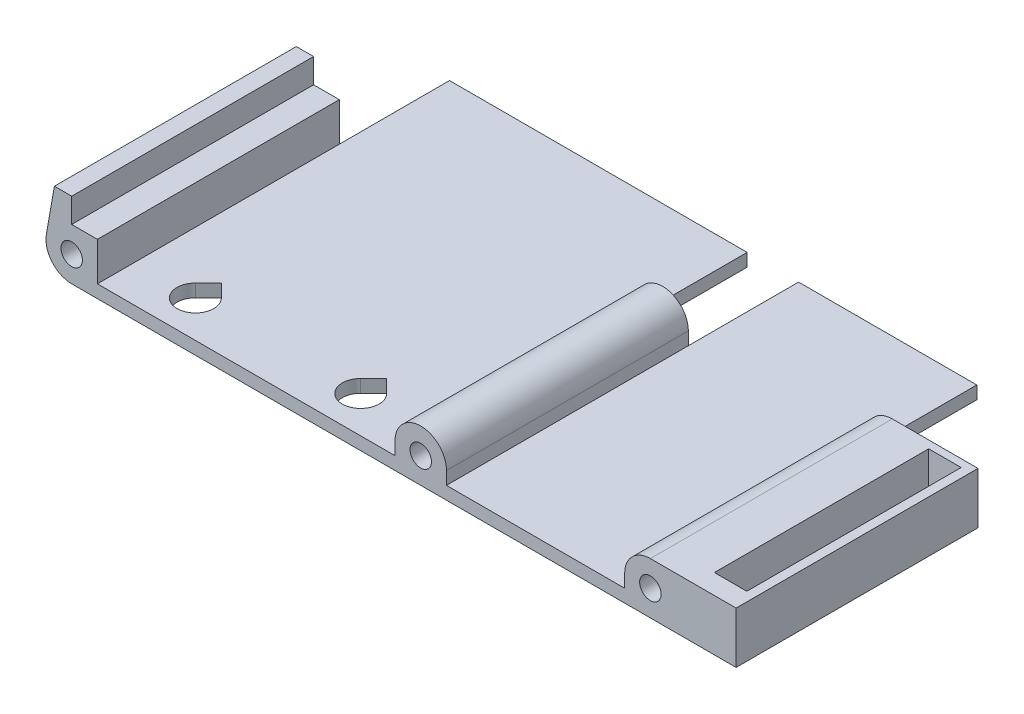
from build123d import *

# Parameters (mm, degrees)
SKETCH1_R           = 1.75
BOSS_EXTRUDE1_DEPTH = 57.5
BOSS_EXTRUDE2_DEPTH = 8.4
SKETCH3_W           = 5.3
SKETCH3_H           = 35
CUT_EXTRUDE1_DEPTH  = 5.4
CUT_EXTRUDE2_DEPTH  = 3.1
SKETCH5_W           = 18.2
SKETCH5_H           = 8.4
SKETCH5_W_2         = 8.4
SKETCH5_H_2         = 8.937392322
SKETCH5_W_3         = 9.875614017
SKETCH5_H_3         = 12.4
CUT_EXTRUDE3_DEPTH  = 18
LPATTERN1_COUNT     = 2
LPATTERN1_PITCH     = 27


with BuildPart() as part:
    # Sketch1 → Boss-Extrude1 (new body)
    with BuildSketch(Plane.XY):
        with BuildLine():
            Line((-52.8, -2.1), (-4.2, -2.1))
            Line((-4.2, -2.1), (-4.2, 0))
            ThreePointArc((-4.2, 0), (0, 4.2), (4.2, 0))
            Line((4.2, 0), (4.2, -2.1))
            Line((4.2, -2.1), (33.3, -2.1))
            Line((33.3, -2.1), (33.3, 0))
            ThreePointArc((33.3, 0), (34.530151519, 2.969848481), (37.5, 4.2))
            Line((37.5, 4.2), (41.5, 4.2))
            Line((41.5, 4.2), (41.5, -4.2))
            Line((41.5, -4.2), (-57, -4.2))
            ThreePointArc((-57, -4.2), (-60.217386661, -2.699707961), (-61.136192563, 0.729322346))
            Line((-61.136192563, 0.729322346), (-59.818910528, 8.2))
            Line((-59.818910528, 8.2), (-57, 8.2))
            Line((-57, 8.2), (-57, 4.2))
            Line((-57, 4.2), (-52.8, 4.2))
            Line((-52.8, 4.2), (-52.8, -2.1))
        make_face()
        Circle(SKETCH1_R, mode=Mode.SUBTRACT)
        with Locations((-57, 0)):
            Circle(SKETCH1_R, mode=Mode.SUBTRACT)
        with Locations((37.5, 0)):
            Circle(SKETCH1_R, mode=Mode.SUBTRACT)
    extrude(amount=BOSS_EXTRUDE1_DEPTH)

    # Sketch2 → Boss-Extrude2 (add)
    with BuildSketch(Plane(origin=(0, 4.2, 0), x_dir=(1, 0, 0), z_dir=(0, 1, 0))):
        Polygon((41.5, -57.5), (51.5, -57.5), (51.5, -17.5), (41.5, 0), align=None)
    extrude(amount=-BOSS_EXTRUDE2_DEPTH)

    # Sketch3 → Cut-Extrude1 (cut)
    with BuildSketch(Plane(origin=(0, 4.2, 0), x_dir=(1, 0, 0), z_dir=(0, 1, 0))):
        with Locations((47.35, -36.75)):
            Rectangle(SKETCH3_W, SKETCH3_H)
    extrude(amount=-CUT_EXTRUDE1_DEPTH, mode=Mode.SUBTRACT)

    # Sketch4 → Cut-Extrude2 (cut, through all)
    with BuildSketch(Plane(origin=(0, -2.1, 0), x_dir=(1, 0, 0), z_dir=(0, 1, 0))):
        with BuildLine():
            Line((-44.921320344, -49.378679656), (-42.8, -47.257359313))
            Line((-42.8, -47.257359313), (-40.678679656, -49.378679656))
            ThreePointArc((-40.678679656, -49.378679656), (-42.8, -54.5), (-44.921320344, -49.378679656))
        make_face()
    cut_extrude2 = extrude(amount=-CUT_EXTRUDE2_DEPTH, mode=Mode.SUBTRACT)

    # Sketch5 → Cut-Extrude3 (cut)
    with BuildSketch(Plane(origin=(0, 0, 0), x_dir=(-1, 0, 0), z_dir=(0, 0, -1))):
        with Locations((-42.4, 0)):
            Rectangle(SKETCH5_W, SKETCH5_H)
        with Locations((0, 0.268696161)):
            Rectangle(SKETCH5_W_2, SKETCH5_H_2)
        with Locations((57.737807008, 2)):
            Rectangle(SKETCH5_W_3, SKETCH5_H_3)
    extrude(amount=-CUT_EXTRUDE3_DEPTH, mode=Mode.SUBTRACT)

    # LPattern1: Cut-Extrude2 ×2
    with Locations(*[(i * LPATTERN1_PITCH, 0, 0) for i in range(1, LPATTERN1_COUNT)]):
        add(cut_extrude2, mode=Mode.SUBTRACT)


solid = part.part
